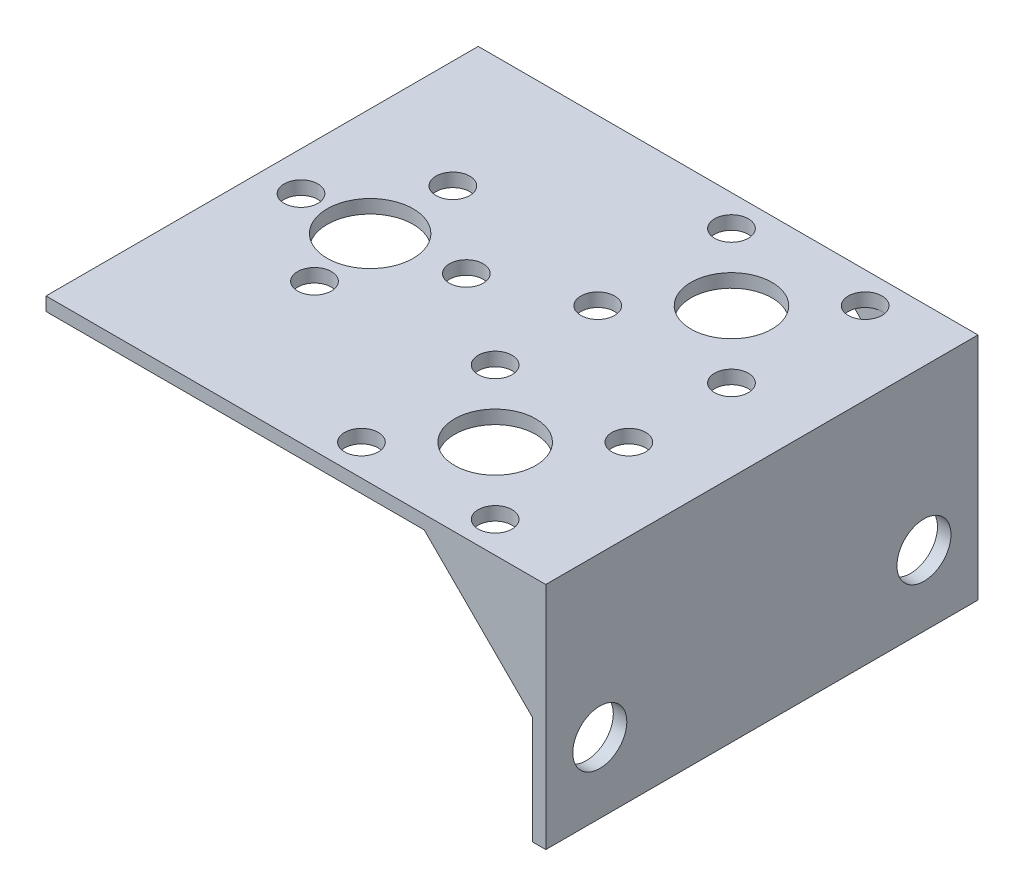
from build123d import *

# Parameters (mm, degrees)
BOSS_EXTRUDE2_DEPTH = 50.8
SKETCH4_R           = 5.05
SKETCH4_R_2         = 4.7625
SKETCH4_R_3         = 1.984375
CUT_EXTRUDE1_DEPTH  = 1.5875
BOSS_EXTRUDE3_DEPTH = 1.5875
BOSS_EXTRUDE4_DEPTH = 1.5875
SKETCH8_R           = 3.175
CUT_EXTRUDE2_DEPTH  = 1.5875


with BuildPart() as part:
    # Sketch3 → Boss-Extrude2 (new body)
    with BuildSketch(Plane.XY):
        Polygon((-121.219673345, 0), (-62.482173345, 0), (-62.482173345, -26.9875), (-64.069673345, -26.9875), (-64.069673345, -1.5875), (-121.219673345, -1.5875), align=None)
    extrude(amount=BOSS_EXTRUDE2_DEPTH)

    # Sketch4 → Cut-Extrude1 (cut)
    with BuildSketch(Plane(origin=(0, 0, 0), x_dir=(1, 0, 0), z_dir=(0, 1, 0))):
        with Locations((-108.519673345, -25.4)):
            Circle(SKETCH4_R)
        with Locations((-79.944673345, -39.2875)):
            Circle(SKETCH4_R_2)
        with Locations((-108.519673345, -15.685)):
            Circle(SKETCH4_R_3)
        with Locations((-87.802397451, -31.429775894)):
            Circle(SKETCH4_R_3)
        with Locations((-72.086949239, -31.429775894)):
            Circle(SKETCH4_R_3)
        with Locations((-72.086949239, -47.145224106)):
            Circle(SKETCH4_R_3)
        with Locations((-87.802397451, -47.145224106)):
            Circle(SKETCH4_R_3)
        with Locations((-116.649673345, -25.4)):
            Circle(SKETCH4_R_3)
        with Locations((-98.804673345, -23.815)):
            Circle(SKETCH4_R_3)
        with Locations((-106.934673345, -33.53)):
            Circle(SKETCH4_R_3)
        with Locations((-87.802397451, -3.654775894)):
            Circle(SKETCH4_R_3)
        with Locations((-72.086949239, -3.654775894)):
            Circle(SKETCH4_R_3)
        with Locations((-72.086949239, -19.370224106)):
            Circle(SKETCH4_R_3)
        with Locations((-87.802397451, -19.370224106)):
            Circle(SKETCH4_R_3)
        with Locations((-79.944673345, -11.5125)):
            Circle(SKETCH4_R_2)
    extrude(amount=-CUT_EXTRUDE1_DEPTH, mode=Mode.SUBTRACT)

    # Sketch5 → Boss-Extrude3 (add)
    with BuildSketch(Plane(origin=(0, 0, 0), x_dir=(-1, 0, 0), z_dir=(0, 0, -1))):
        Polygon((76.769673345, -1.5875), (64.069673345, -14.2875), (64.069673345, -1.5875), align=None)
    extrude(amount=-BOSS_EXTRUDE3_DEPTH)

    # Sketch7 → Boss-Extrude4 (add)
    with BuildSketch(Plane.XY.offset(50.8)):
        Polygon((-64.069673345, -1.5875), (-64.069673345, -14.2875), (-76.769673345, -1.5875), align=None)
    extrude(amount=-BOSS_EXTRUDE4_DEPTH)

    # Sketch8 → Cut-Extrude2 (cut)
    with BuildSketch(Plane(origin=(-62.482173345, 0, 0), x_dir=(0, 0, -1), z_dir=(1, 0, 0))):
        with Locations((-44.45, -18.725361779)):
            Circle(SKETCH8_R)
        with Locations((-6.35, -18.725361779)):
            Circle(SKETCH8_R)
    extrude(amount=-CUT_EXTRUDE2_DEPTH, mode=Mode.SUBTRACT)


solid = part.part
